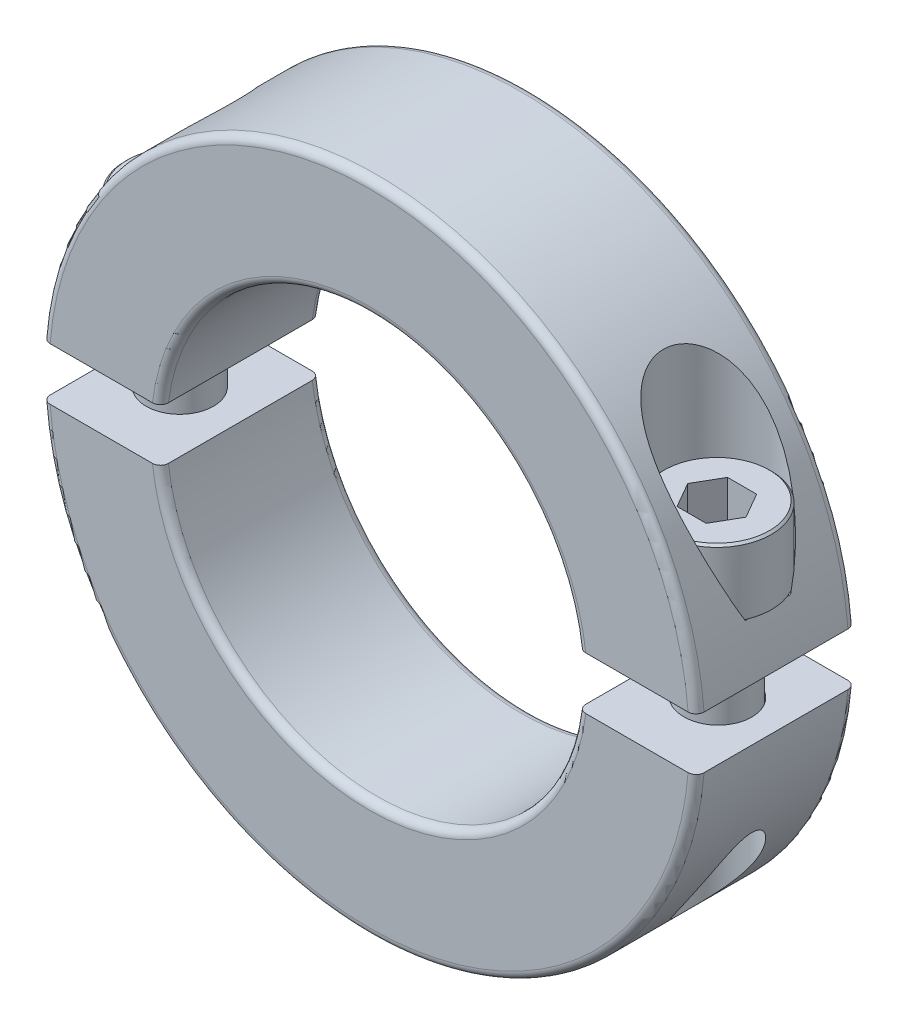
from build123d import *

# Parameters (mm, degrees)
EXTRUDE1_DEPTH     = 9.5
EXTRUDE1_2_DEPTH   = 9.5
FILLET1_R          = 0.95
FILLET2_R          = 0.95
SKETCH8_R          = 4
CUT_EXTRUDE3_DEPTH = 63.586340517
CUT_EXTRUDE2_DEPTH = 6
CHAMFER1_SIZE      = 0.254
CHAMFER2_SIZE      = 1.25
LPATTERN1_COUNT    = 2
LPATTERN1_PITCH    = 63.839773824


with BuildPart() as part:
    # Sketch1 → Extrude1 (new, symmetric)
    with BuildSketch(Plane.XY):
        with BuildLine():
            Line((-38.874999678, 3.12), (-24.80454797, 3.12))
            ThreePointArc((-24.80454797, 3.12), (0, 25), (24.80454797, 3.12))
            Line((24.80454797, 3.12), (38.874999678, 3.12))
            ThreePointArc((38.874999678, 3.12), (0, 39), (-38.874999678, 3.12))
        make_face()
    extrude(amount=EXTRUDE1_DEPTH, both=True)

    # Fillet1
    fillet1_edges = [part.edges().sort_by_distance(p)[0] for p in [
        (0, 25, 9.5),
        (0, 25, -9.5),
        (0, 39, -9.5),
        (0, 39, 9.5),
    ]]
    fillet(fillet1_edges, radius=FILLET1_R)


with BuildPart() as body_2:
    # Sketch1 → Extrude1 2 (new, symmetric)
    with BuildSketch(Plane.XY):
        with BuildLine():
            Line((-38.874999678, -3.12), (-24.80454797, -3.12))
            ThreePointArc((-24.80454797, -3.12), (0, -25), (24.80454797, -3.12))
            Line((24.80454797, -3.12), (38.874999678, -3.12))
            ThreePointArc((38.874999678, -3.12), (0, -39), (-38.874999678, -3.12))
        make_face()
    extrude(amount=EXTRUDE1_2_DEPTH, both=True)

    # Fillet2
    fillet2_edges = [body_2.edges().sort_by_distance(p)[0] for p in [
        (0, -39, 9.5),
        (0, -25, 9.5),
        (0, -25, -9.5),
        (0, -39, -9.5),
    ]]
    fillet(fillet2_edges, radius=FILLET2_R)


with BuildPart() as cut_revolve1_tool:
    # Sketch2 → Cut-Revolve1 (revolve)
    with BuildSketch(Plane(origin=(0, 0, 0), x_dir=(1, 0, 0), z_dir=(0, 1, 0))):
        with BuildLine():
            Line((-32.1905, 9.5), (-31.8095, 9.5))
            ThreePointArc((-31.8095, 9.5), (-32, 9.3095), (-32.1905, 9.5))
        make_face()
    revolve(axis=Axis((0, 0, -9.5), (0, 0, 1)))


with BuildPart() as part_1:
    add(part.part)

    # Cut-Revolve1: cut by cut_revolve1_tool
    add(cut_revolve1_tool.part, mode=Mode.SUBTRACT)


with BuildPart() as body_2_1:
    add(body_2.part)

    # Cut-Revolve1: cut by cut_revolve1_tool
    add(cut_revolve1_tool.part, mode=Mode.SUBTRACT)


with BuildPart() as cut_revolve2_tool:
    # Sketch3 → Cut-Revolve2 (revolve)
    with BuildSketch(Plane.XY):
        Polygon((-32, 39), (-25.4975, 39), (-25.4975, 9.12), (-28, 9.12), (-28, -39), (-32, -39), align=None)
    cut_revolve2 = revolve(axis=Axis((-32, -39, 0), (0, 1, 0)))


with BuildPart() as part_2:
    add(part_1.part)

    # Cut-Revolve2: cut by cut_revolve2_tool
    add(cut_revolve2_tool.part, mode=Mode.SUBTRACT)

    # Mirror1: Cut-Revolve2 across plane
    add(cut_revolve2.mirror(Plane(origin=(0, 0, 0), x_dir=(0, 0, 1), z_dir=(1, 0, 0))), mode=Mode.SUBTRACT)


with BuildPart() as body_2_2:
    add(body_2_1.part)

    # Cut-Revolve2: cut by cut_revolve2_tool
    add(cut_revolve2_tool.part, mode=Mode.SUBTRACT)

    # Sketch8 → Cut-Extrude3 (cut, through all)
    with BuildSketch(Plane(origin=(0, 9.12, 0), x_dir=(1, 0, 0), z_dir=(0, 1, 0))):
        with Locations((32, 0)):
            Circle(SKETCH8_R)
    extrude(amount=-CUT_EXTRUDE3_DEPTH, mode=Mode.SUBTRACT)


with BuildPart() as body_3:
    # Sketch4 → Revolve1 (revolve)
    with BuildSketch(Plane.XY):
        Polygon((-32, 17.12), (-25.5, 17.12), (-25.5, 9.12), (-28, 9.12), (-28, -15.88), (-32, -15.88), align=None)
    revolve(axis=Axis((-32, -15.88, 0), (0, 1, 0)))

    # Sketch5 → Cut-Extrude2 (cut)
    with BuildSketch(Plane(origin=(0, 17.12, 0), x_dir=(-1, 0, 0), z_dir=(0, 1, 0))):
        Polygon((33.732050808, -3), (35.464101615, 0), (33.732050808, 3), (30.267949192, 3), (28.535898385, 0), (30.267949192, -3), align=None)
    extrude(amount=-CUT_EXTRUDE2_DEPTH, mode=Mode.SUBTRACT)

    # Chamfer1
    chamfer1_edges = [body_3.edges().sort_by_distance(p)[0] for p in [
        (-38.5, 17.12, 0),
    ]]
    chamfer(chamfer1_edges, length=CHAMFER1_SIZE)

    # Chamfer2
    chamfer2_edges = [body_3.edges().sort_by_distance(p)[0] for p in [
        (-36, -15.88, 0),
    ]]
    chamfer(chamfer2_edges, length=CHAMFER2_SIZE)


with BuildPart() as lpattern1_1:
    # LPattern1: pattern copy
    add(body_3.part.moved(Location(Vector(1, 0, 0) * (1 * LPATTERN1_PITCH))))


solid = Compound([part_2.part, body_2_2.part, body_3.part, lpattern1_1.part])
